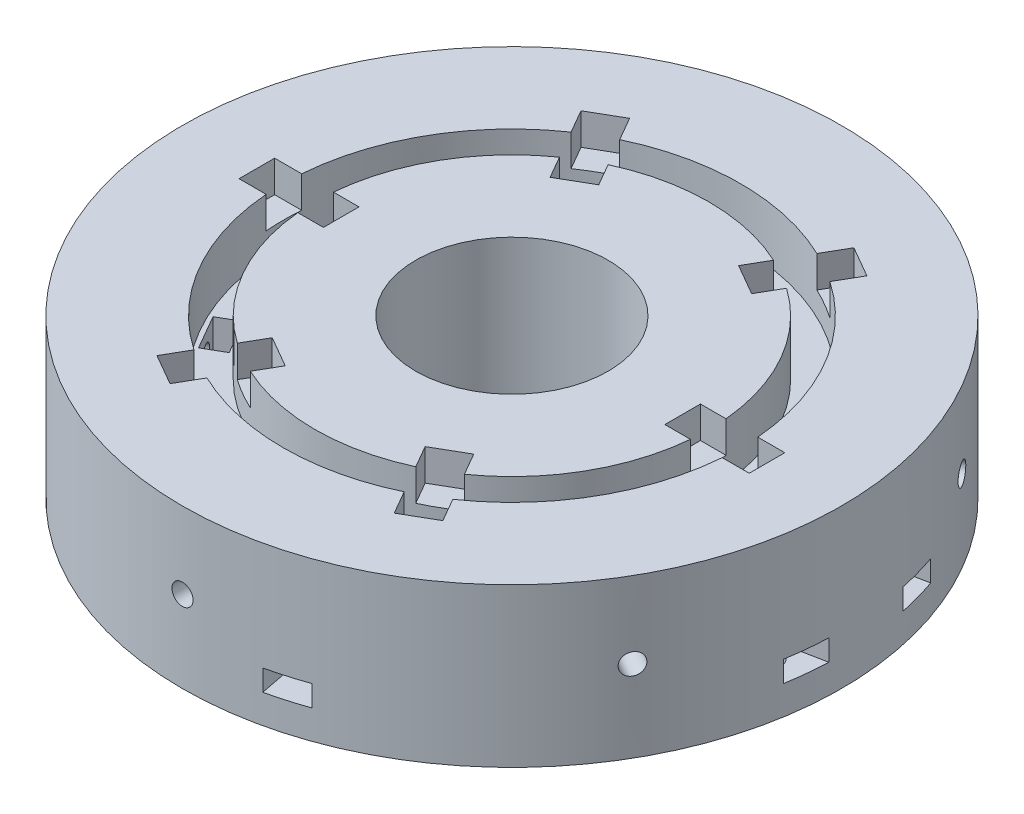
from build123d import *

# Parameters (mm, degrees)
SKETCH1_R           = 62.5
SKETCH1_R_2         = 18.25
BOSS_EXTRUDE1_DEPTH = 30
SKETCH2_W           = 16
SKETCH2_H           = 6.75
CUT_EXTRUDE2_DEPTH  = 6
SKETCH3_R           = 43.375
SKETCH3_R_2         = 37.375
CUT_EXTRUDE3_DEPTH  = 10.5
SKETCH5_W           = 7.5
SKETCH5_H           = 4.25
CUT_EXTRUDE5_DEPTH  = 8
CUT_EXTRUDE6_START  = -43.876587737
SKETCH6_R           = 2
CUT_EXTRUDE6_DEPTH  = 53.876587737
CIRPATTERN1_COUNT   = 6
SKETCH7_R           = 2
CUT_EXTRUDE7_DEPTH  = 9.5
CUT_EXTRUDE8_DEPTH  = 4


with BuildPart() as part:
    # Sketch1 → Boss-Extrude1 (new body)
    with BuildSketch(Plane(origin=(0, 0, 0), x_dir=(1, 0, 0), z_dir=(0, 1, 0))):
        Circle(SKETCH1_R)
        Circle(SKETCH1_R_2, mode=Mode.SUBTRACT)
    extrude(amount=BOSS_EXTRUDE1_DEPTH)

    # Sketch2 → Cut-Extrude2 (cut)
    with BuildSketch(Plane(origin=(0, 30, 0), x_dir=(1, 0, 0), z_dir=(0, 1, 0))):
        with Locations((40.375, 0)):
            Rectangle(SKETCH2_W, SKETCH2_H)
        Polygon((19.110335738, -26.350072448), (13.264664262, -29.725072448), (21.264664262, -43.581478908), (27.110335738, -40.206478908), align=None)
        Polygon((-13.264664262, -29.725072448), (-19.110335738, -26.350072448), (-27.110335738, -40.206478908), (-21.264664262, -43.581478908), align=None)
        with Locations((-40.375, 0)):
            Rectangle(SKETCH2_W, SKETCH2_H)
        Polygon((-19.110335738, 26.350072448), (-13.264664262, 29.725072448), (-21.264664262, 43.581478908), (-27.110335738, 40.206478908), align=None)
        Polygon((13.264664262, 29.725072448), (19.110335738, 26.350072448), (27.110335738, 40.206478908), (21.264664262, 43.581478908), align=None)
    extrude(amount=-CUT_EXTRUDE2_DEPTH, mode=Mode.SUBTRACT)

    # Sketch3 → Cut-Extrude3 (cut)
    with BuildSketch(Plane(origin=(0, 30, 0), x_dir=(1, 0, 0), z_dir=(0, 1, 0))):
        Circle(SKETCH3_R)
        Circle(SKETCH3_R_2, mode=Mode.SUBTRACT)
    extrude(amount=-CUT_EXTRUDE3_DEPTH, mode=Mode.SUBTRACT)

    # Sketch5 → Cut-Extrude5 (cut)
    with BuildSketch(Plane(origin=(0, 19.5, 0), x_dir=(1, 0, 0), z_dir=(0, 1, 0))):
        with Locations((0, 40.375)):
            Rectangle(SKETCH5_W, SKETCH5_H)
        Polygon((34.931079661, 24.497595264), (31.250471695, 22.372595264), (35.000471695, 15.877404736), (38.681079661, 18.002404736), align=None)
        Polygon((38.681079661, -18.002404736), (35.000471695, -15.877404736), (31.250471695, -22.372595264), (34.931079661, -24.497595264), align=None)
        with Locations((0, -40.375)):
            Rectangle(SKETCH5_W, SKETCH5_H)
        Polygon((-34.931079661, -24.497595264), (-31.250471695, -22.372595264), (-35.000471695, -15.877404736), (-38.681079661, -18.002404736), align=None)
        Polygon((-38.681079661, 18.002404736), (-35.000471695, 15.877404736), (-31.250471695, 22.372595264), (-34.931079661, 24.497595264), align=None)
    extrude(amount=-CUT_EXTRUDE5_DEPTH, mode=Mode.SUBTRACT)

    # Sketch6 → Cut-Extrude6 (cut)
    with BuildSketch(Plane(origin=(36.806079661, 0, -21.25), x_dir=(0.5, 0, 0.866025404), z_dir=(-0.866025404, 0, 0.5)).offset(CUT_EXTRUDE6_START)):
        with Locations((0, 15.5)):
            Circle(SKETCH6_R)
    cut_extrude6 = extrude(amount=CUT_EXTRUDE6_DEPTH, mode=Mode.SUBTRACT)

    # CirPattern1: Cut-Extrude6 ×6 about axis
    cirpattern1_axis = Axis((0, 0, 0), (0, 1, 0))
    for i in range(1, CIRPATTERN1_COUNT):
        add(cut_extrude6.rotate(cirpattern1_axis, i * 360 / CIRPATTERN1_COUNT), mode=Mode.SUBTRACT)

    # Sketch7 → Cut-Extrude7 (cut)
    with BuildSketch(Plane.XZ):
        with Locations((15.703618414, 51.574778515)):
            Circle(SKETCH7_R)
        with Locations((56.522842607, 7.359909212)):
            Circle(SKETCH7_R)
        with Locations((52.093237989, -15.110557172)):
            Circle(SKETCH7_R)
    extrude(amount=-CUT_EXTRUDE7_DEPTH, mode=Mode.SUBTRACT)

    # Sketch8 → Cut-Extrude8 (cut)
    with BuildSketch(Plane.XZ.offset(-9.5)):
        with BuildLine():
            Line((12.443164797, 54.42424201), (13.733993709, 60.972349609))
            ThreePointArc((13.733993709, 60.972349609), (17.381349368, 60.034479211), (20.965596862, 58.878635754))
            Line((20.965596862, 58.878635754), (19.801552997, 52.973682427))
            Line((19.801552997, 52.973682427), (18.964072031, 48.725315019))
            Line((18.964072031, 48.725315019), (14.866137449, 47.326411107))
            Line((14.866137449, 47.326411107), (11.605683832, 50.175874602))
            Line((11.605683832, 50.175874602), (12.443164797, 54.42424201))
        make_face()
        with BuildLine():
            Line((54.942701485, -11.850103555), (50.694334077, -11.012622589))
            Line((50.694334077, -11.012622589), (47.844870581, -14.273076206))
            Line((47.844870581, -14.273076206), (49.243774494, -18.371010788))
            Line((49.243774494, -18.371010788), (53.492141902, -19.208491754))
            Line((53.492141902, -19.208491754), (59.106200943, -20.315191608))
            ThreePointArc((59.106200943, -20.315191608), (60.22155233, -16.721681583), (61.118644269, -13.06756759))
            Line((61.118644269, -13.06756759), (54.942701485, -11.850103555))
        make_face()
        with BuildLine():
            Line((59.372306103, 10.620362829), (55.123938695, 11.457843794))
            Line((55.123938695, 11.457843794), (52.274475199, 8.197390178))
            Line((52.274475199, 8.197390178), (53.673379112, 4.099455595))
            Line((53.673379112, 4.099455595), (57.92174652, 3.261974629))
            Line((57.92174652, 3.261974629), (62.455112673, 2.368311841))
            ThreePointArc((62.455112673, 2.368311841), (62.183643054, 6.280488561), (61.667357766, 10.167939133))
            Line((61.667357766, 10.167939133), (59.372306103, 10.620362829))
        make_face()
    extrude(amount=CUT_EXTRUDE8_DEPTH, mode=Mode.SUBTRACT)


solid = part.part
